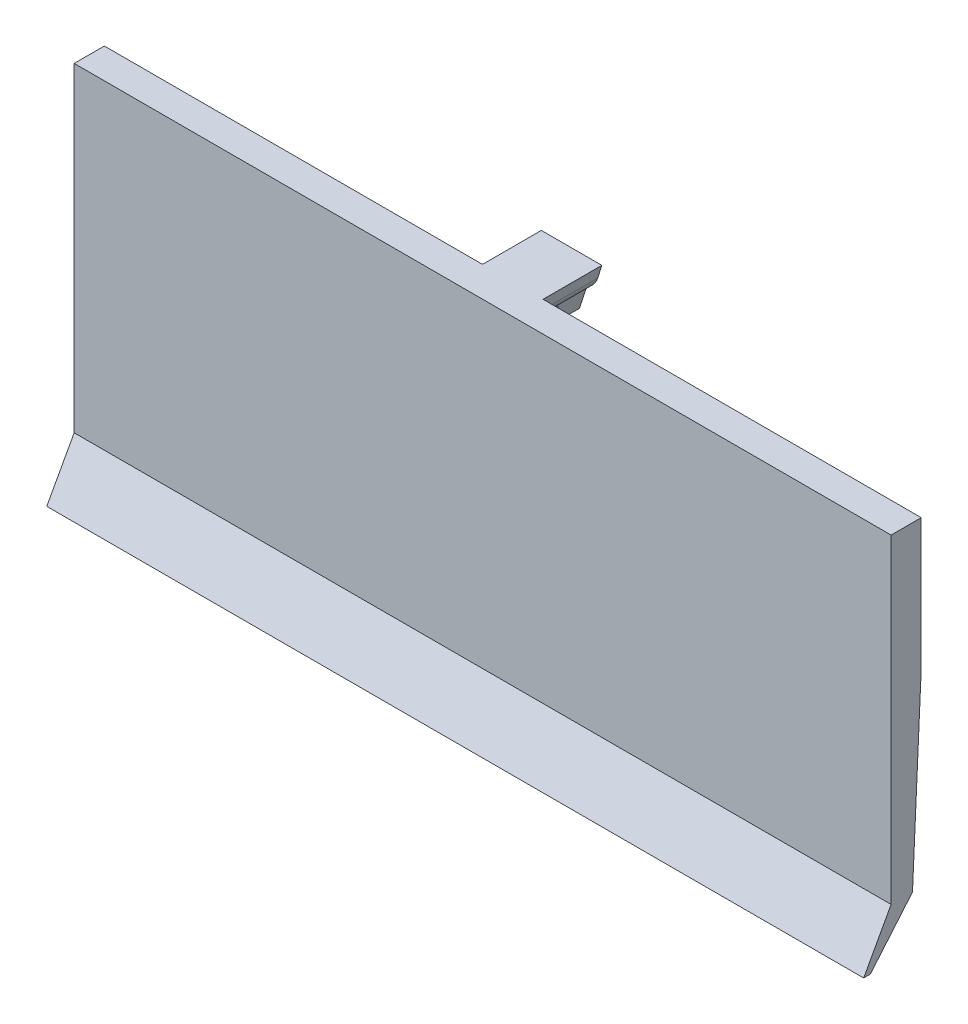
from build123d import *

# Parameters (mm, degrees)
EXTRUDE_1_DEPTH      = 27
SKETCH_2_W           = 9
SKETCH_2_H           = 4
CUT_EXTRUDE_1_DEPTH  = 4
SKETCH_3_W           = 9
SKETCH_3_H           = 3.038101075
EXTRUDE_2_DEPTH      = 3
SKETCH_4_R           = 1.5
CUT_EXTRUDE_2_DEPTH  = 9
EXTRUDE_3_DEPTH      = 2
CUT_EXTRUDE_8_DEPTH  = 3.887469
SKETCH_8_W           = 8.610608055
SKETCH_8_H           = 13.248031464
CUT_EXTRUDE_9_DEPTH  = 54
EXTRUDE_4_DEPTH      = 54
SKETCH_12_W          = 24
SKETCH_12_H          = 6.005920689
SKETCH_12_H_2        = 6.032486627
EXTRUDE_6_DEPTH      = 2.215161
EXTRUDE_7_DEPTH      = 54
CUT_EXTRUDE_11_DEPTH = 54


with BuildPart() as part:
    # 草图1 → 凸台-拉伸1 (new body, symmetric)
    with BuildSketch(Plane(origin=(0, 0, 0), x_dir=(0, 0, -1), z_dir=(1, 0, 0))):
        Polygon((6.496390194, -5.234874936), (6.496390194, -1.191259859), (6.496390194, 1.388117725), (6.496390194, 3.400940667), (2.492073736, 5.926640843), (1.992780388, 6.907616744), (1.992780388, 8.966437233), (1.992780388, 13.434908234), (1.992780388, 15.531060696), (0, 15.531060696), (0, 13.265125064), (0, 9.02431695), (0, 5.531060696), (1.075983727, 5.531060696), (2.127060271, 3.7449116), (2.127060271, 3.316049082), (3.852001832, 3.316049082), (3.852001832, -5.234874936), align=None)
    extrude(amount=EXTRUDE_1_DEPTH, both=True)

    # 草图2 → 切除-拉伸1 (cut)
    with BuildSketch(Plane(origin=(0, 0, -6.496390194), x_dir=(-1, 0, 0), z_dir=(0, 0, -1))):
        with Locations((0, -3.734874936)):
            Rectangle(SKETCH_2_W, SKETCH_2_H)
    extrude(amount=-CUT_EXTRUDE_1_DEPTH, mode=Mode.SUBTRACT)

    # 草图3 → 凸台-拉伸2 (add)
    with BuildSketch(Plane(origin=(0, 0, -6.496390194), x_dir=(-1, 0, 0), z_dir=(0, 0, -1))):
        with Locations((0, -0.215824399)):
            Rectangle(SKETCH_3_W, SKETCH_3_H)
    extrude(amount=EXTRUDE_2_DEPTH)

    # 草图4 → 切除-拉伸2 (cut)
    with BuildSketch(Plane.XZ.offset(1.734874936)):
        with Locations((0, -6.102001832)):
            Circle(SKETCH_4_R)
    extrude(amount=-CUT_EXTRUDE_2_DEPTH, mode=Mode.SUBTRACT)

    # 草图6 → 凸台-拉伸3 (add, symmetric)
    with BuildSketch(Plane(origin=(0, 0, 0), x_dir=(0, 0, -1), z_dir=(1, 0, 0))):
        Polygon((1.880249614, 15.531060696), (5.880249614, 15.531060696), (5.880249614, 12.331060696), (4.080249614, 12.331060696), (4.080249614, 13.531060696), (2.0593477, 13.531060696), (1.880249614, 13.531060696), align=None)
    extrude(amount=EXTRUDE_3_DEPTH, both=True)

    # 草图7 → 切除-拉伸8 (cut)
    with BuildSketch(Plane(origin=(0, 0, -5.880249614), x_dir=(-1, 0, 0), z_dir=(0, 0, -1))):
        with BuildLine():
            Line((1, 13.831060696), (0.52341558, 12.331060696))
            Line((0.52341558, 12.331060696), (2, 12.331060696))
            Line((2, 12.331060696), (2, 15.531060696))
            Line((2, 15.531060696), (1.723060875, 14.659423543))
            ThreePointArc((1.723060875, 14.659423543), (1.447645575, 14.170073989), (1, 13.831060696))
        make_face()
        with BuildLine():
            ThreePointArc((-1.723060875, 14.659423543), (-1.447645575, 14.170073989), (-1, 13.831060696))
            Line((-1, 13.831060696), (-0.52341558, 12.331060696))
            Line((-0.52341558, 12.331060696), (-2, 12.331060696))
            Line((-2, 12.331060696), (-2, 15.531060696))
            Line((-2, 15.531060696), (-1.723060875, 14.659423543))
        make_face()
    extrude(amount=-CUT_EXTRUDE_8_DEPTH, mode=Mode.SUBTRACT)

    # 草图8 → 切除-拉伸9 (cut)
    with BuildSketch(Plane.ZY.offset(27)):
        with Locations((-8.09764747, -1.373941145)):
            Rectangle(SKETCH_8_W, SKETCH_8_H)
    extrude(amount=-CUT_EXTRUDE_9_DEPTH, mode=Mode.SUBTRACT)

    # 草图9 → 凸台-拉伸4 (add)
    with BuildSketch(Plane.ZY.offset(27)):
        Polygon((-2.215161152, 3.316049082), (-2.127060271, 3.316049082), (-2.215161152, 0.39188408), (-2.215161152, -5.614036609), (-3.792343442, -5.614036609), (-3.792343442, 3.316049082), align=None)
    extrude(amount=-EXTRUDE_4_DEPTH)

    # 草图12 → 凸台-拉伸6 (add)
    with BuildSketch(Plane.XY.offset(-2.215161152)):
        with Locations((-15, -2.611076265)):
            Rectangle(SKETCH_12_W, SKETCH_12_H)
        with Locations((15, -2.597793296)):
            Rectangle(SKETCH_12_W, SKETCH_12_H_2)
    extrude(amount=EXTRUDE_6_DEPTH)

    # 草图14 → 凸台-拉伸7 (add)
    with BuildSketch(Plane(origin=(27, 0, 0), x_dir=(0, 0, -1), z_dir=(1, 0, 0))):
        Polygon((0, 5.531060696), (0, 0.203028752), (0, -5.614036609), (-1.811628389, -8.919351055), (-1.370090128, -8.919351055), (1.414080713, -5.614036609), (1.992780388, 6.907616744), (0, 6.907616744), align=None)
    extrude(amount=-EXTRUDE_7_DEPTH)

    # 草图15 → 切除-拉伸11 (cut)
    with BuildSketch(Plane(origin=(27, 0, 0), x_dir=(0, 0, -1), z_dir=(1, 0, 0))):
        Polygon((1.992780388, 6.907616744), (1.414080713, -5.614036609), (3.792343442, -5.614036609), (3.792343442, 5.106503009), align=None)
    extrude(amount=-CUT_EXTRUDE_11_DEPTH, mode=Mode.SUBTRACT)


solid = part.part
